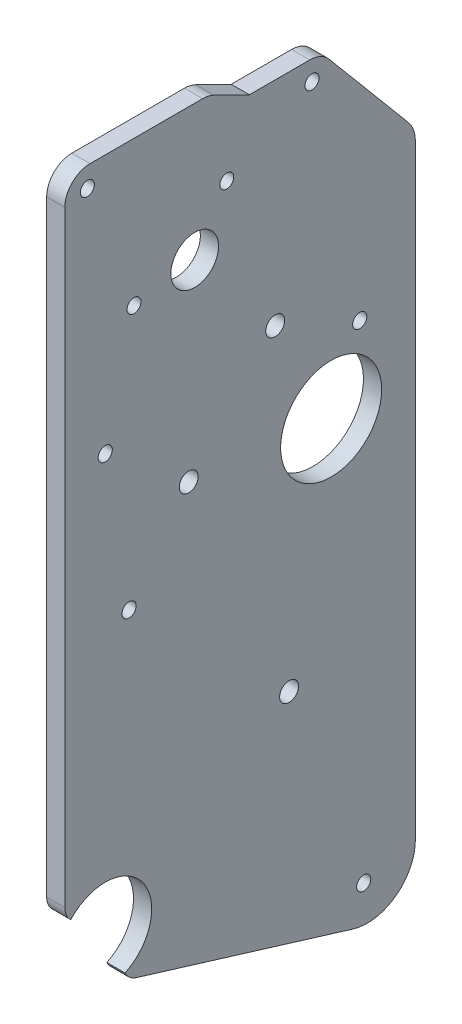
from build123d import *

# Parameters (mm, degrees)
SKETCH4_R           = 12.7
SKETCH4_R_2         = 1.778
SKETCH4_R_3         = 2.38125
SKETCH4_R_4         = 1.75
SKETCH4_R_5         = 6
BOSS_EXTRUDE1_DEPTH = 4.572


with BuildPart() as part:
    # Sketch4 → Boss-Extrude1 (new body)
    with BuildSketch(Plane(origin=(0, 0, 0), x_dir=(0, 0, -1), z_dir=(1, 0, 0))):
        with BuildLine():
            Line((-278.598048041, 44.43052094), (-224.024344082, 27.750173837))
            ThreePointArc((-224.024344082, 27.750173837), (-213.286752868, 29.595855882), (-208.38308557, 39.325010744))
            Line((-208.38308557, 39.325010744), (-208.38308557, 191.588495768))
            ThreePointArc((-208.38308557, 191.588495768), (-208.8426278, 194.19468926), (-210.165826914, 196.486537353))
            Line((-210.165826914, 196.486537353), (-230.07024685, 220.207701322))
            ThreePointArc((-230.07024685, 220.207701322), (-232.251003102, 221.881054448), (-234.934629064, 222.476))
            Line((-234.934629064, 222.476), (-250.119258716, 222.476))
            Line((-250.119258716, 222.476), (-259.069094553, 226.862369804))
            ThreePointArc((-259.069094553, 226.862369804), (-260.42931468, 227.346249494), (-261.863679558, 227.510370624))
            Line((-261.863679558, 227.510370624), (-290.181258716, 227.510370624))
            ThreePointArc((-290.181258716, 227.510370624), (-294.671386777, 225.650498684), (-296.531258716, 221.160370624))
            Line((-296.531258716, 221.160370624), (-296.531258716, 68.663949573))
            ThreePointArc((-296.531258716, 68.663949573), (-296.13893545, 66.810982655), (-295.029296163, 65.276021876))
            ThreePointArc((-295.029296163, 65.276021876), (-276.979257712, 64.380634873), (-281.39899141, 46.857177452))
            ThreePointArc((-281.39899141, 46.857177452), (-280.255414168, 45.347331423), (-278.598048041, 44.43052094))
        make_face()
        with Locations((-229.557259723, 141.660587995)):
            Circle(SKETCH4_R, mode=Mode.SUBTRACT)
        with Locations((-221.371258716, 36.430370624)):
            Circle(SKETCH4_R_2, mode=Mode.SUBTRACT)
        with Locations((-243.629318942, 168.931188955)):
            Circle(SKETCH4_R_3, mode=Mode.SUBTRACT)
        with Locations((-280.371258716, 125.430370624)):
            Circle(SKETCH4_R_2, mode=Mode.SUBTRACT)
        with Locations((-286.371258716, 162.430370624)):
            Circle(SKETCH4_R_2, mode=Mode.SUBTRACT)
        with Locations((-279.132211518, 191.06840303)):
            Circle(SKETCH4_R_4, mode=Mode.SUBTRACT)
        with Locations((-255.799163122, 206.546414937)):
            Circle(SKETCH4_R_4, mode=Mode.SUBTRACT)
        with Locations((-263.872577413, 193.390808463)):
            Circle(SKETCH4_R_5, mode=Mode.SUBTRACT)
        with Locations((-290.871258716, 222.430370624)):
            Circle(SKETCH4_R_2, mode=Mode.SUBTRACT)
        with Locations((-234.371258716, 217.430370624)):
            Circle(SKETCH4_R_2, mode=Mode.SUBTRACT)
        with Locations((-222.371258716, 159.430370624)):
            Circle(SKETCH4_R_2, mode=Mode.SUBTRACT)
        with Locations((-265.366688027, 145.789251152)):
            Circle(SKETCH4_R_3, mode=Mode.SUBTRACT)
        with Locations((-240.13308557, 87.518200818)):
            Circle(SKETCH4_R_3, mode=Mode.SUBTRACT)
    extrude(amount=-BOSS_EXTRUDE1_DEPTH)


solid = part.part
